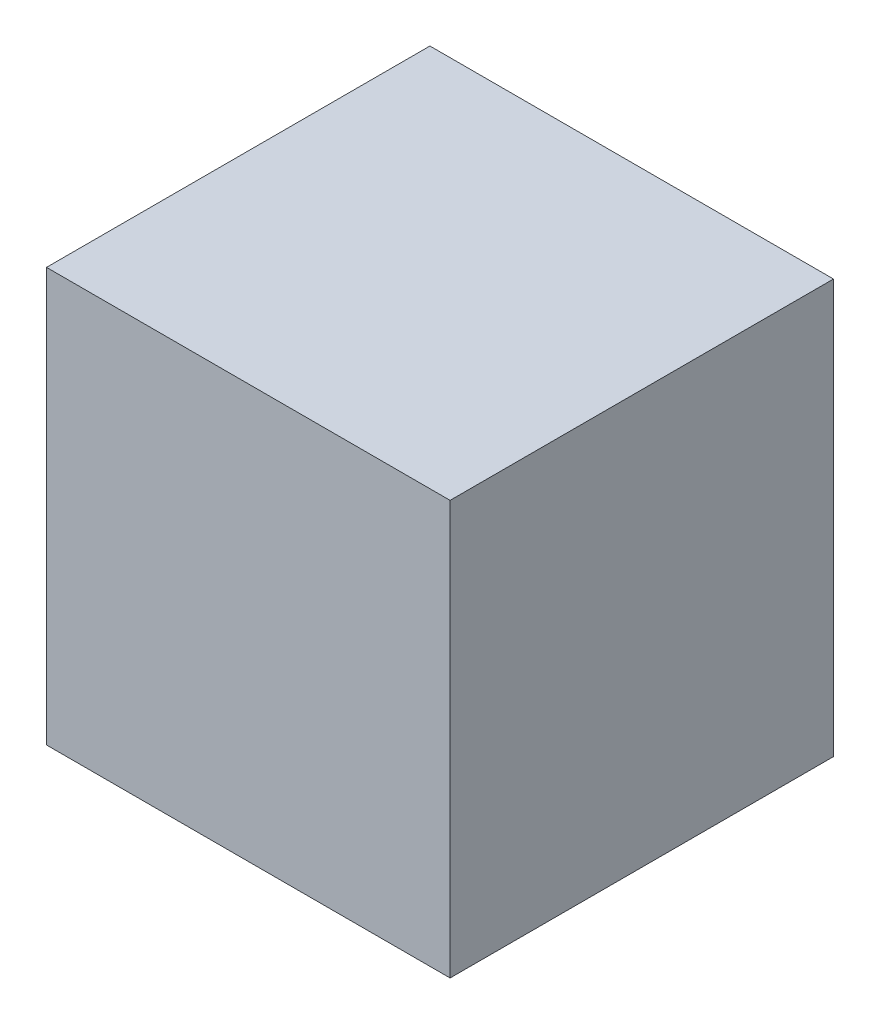
from build123d import *

# Parameters (mm, degrees)
SKETCH1_W           = 40
SKETCH1_H           = 38
BOSS_EXTRUDE1_DEPTH = 41


with BuildPart() as part:
    # Sketch1 → Boss-Extrude1 (new body)
    with BuildSketch(Plane(origin=(0, 0, 0), x_dir=(1, 0, 0), z_dir=(0, 1, 0))):
        Rectangle(SKETCH1_W, SKETCH1_H)
    extrude(amount=BOSS_EXTRUDE1_DEPTH)


solid = part.part
